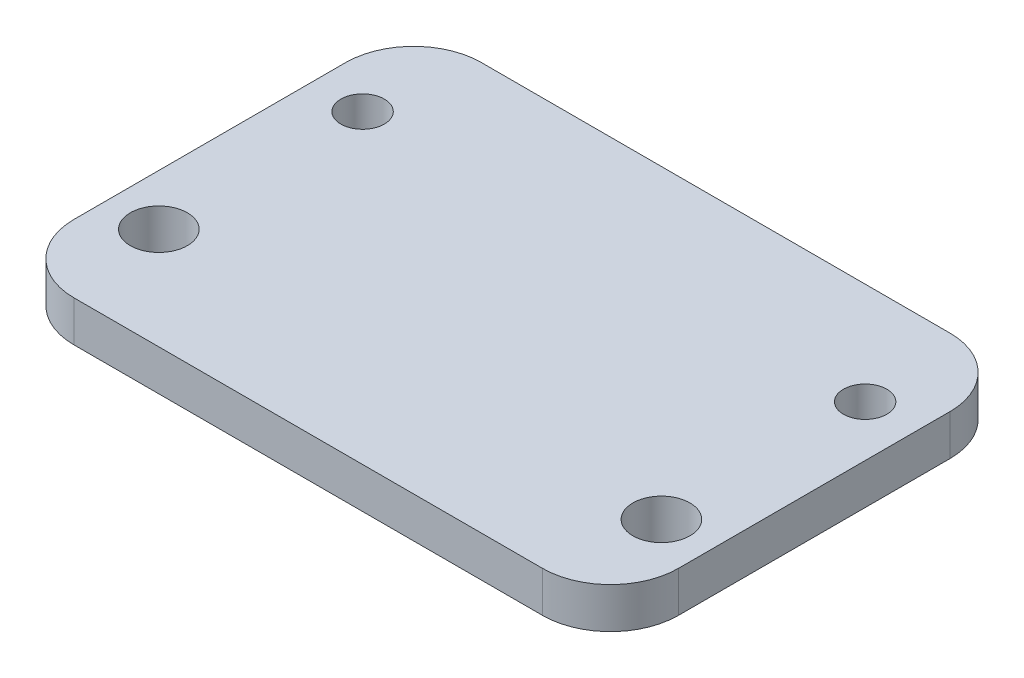
from build123d import *

# Parameters (mm, degrees)
SKETCH_1_W          = 44.5
SKETCH_1_H          = 30
EXTRUDE_1_DEPTH     = 3
SKETCH_2_R          = 1.6
SKETCH_2_R_2        = 2.1
CUT_EXTRUDE_1_DEPTH = 3
FILLET_1_R          = 5


with BuildPart() as part:
    # ｽｹｯﾁ1 → ﾎﾞｽ - 押し出し1 (new body)
    with BuildSketch(Plane(origin=(0, 0, 0), x_dir=(1, 0, 0), z_dir=(0, 1, 0))):
        with Locations((22.25, 15)):
            Rectangle(SKETCH_1_W, SKETCH_1_H)
    extrude(amount=EXTRUDE_1_DEPTH)

    # ｽｹｯﾁ2 → ｶｯﾄ - 押し出し1 (cut)
    with BuildSketch(Plane(origin=(0, 3, 0), x_dir=(1, 0, 0), z_dir=(0, 1, 0))):
        with Locations((3.75, 22.5)):
            Circle(SKETCH_2_R)
        with Locations((40.75, 22.5)):
            Circle(SKETCH_2_R)
        with Locations((3.75, 7.5)):
            Circle(SKETCH_2_R_2)
        with Locations((40.75, 7.5)):
            Circle(SKETCH_2_R_2)
    extrude(amount=-CUT_EXTRUDE_1_DEPTH, mode=Mode.SUBTRACT)

    # ﾌｨﾚｯﾄ1
    fillet_1_edges = [part.edges().sort_by_distance(p)[0] for p in [
        (0, 1.5, -30),
        (44.5, 1.5, -30),
        (44.5, 1.5, 0),
        (0, 1.5, 0),
    ]]
    fillet(fillet_1_edges, radius=FILLET_1_R)


solid = part.part
